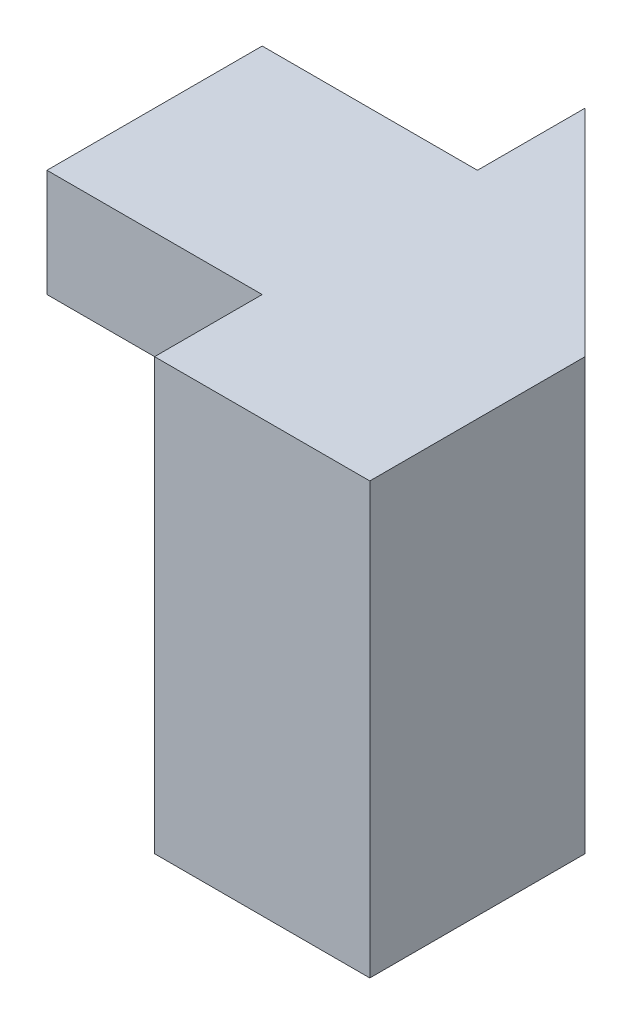
from build123d import *

# Parameters (mm, degrees)
BOSS_EXTRUDE1_DEPTH = 4
SKETCH2_W           = 1
SKETCH2_H           = 3
CUT_EXTRUDE1_DEPTH  = 2


with BuildPart() as part:
    # Sketch1 → Boss-Extrude1 (new body)
    with BuildSketch(Plane(origin=(0, 0, 0), x_dir=(1, 0, 0), z_dir=(0, 1, 0))):
        Polygon((0, 0), (2, 0), (2, 2), (0, 4), (-2, 4), (-2, 1), (0, 1), align=None)
    extrude(amount=BOSS_EXTRUDE1_DEPTH)

    # Sketch2 → Cut-Extrude1 (cut)
    with BuildSketch(Plane.ZY.offset(2)):
        with Locations((-1.5, 1.5)):
            Rectangle(SKETCH2_W, SKETCH2_H)
        Polygon((-3, 4), (-3, 2), (-4, 0), (-4, 2), (-4, 4), align=None)
    extrude(amount=-CUT_EXTRUDE1_DEPTH, mode=Mode.SUBTRACT)


solid = part.part
